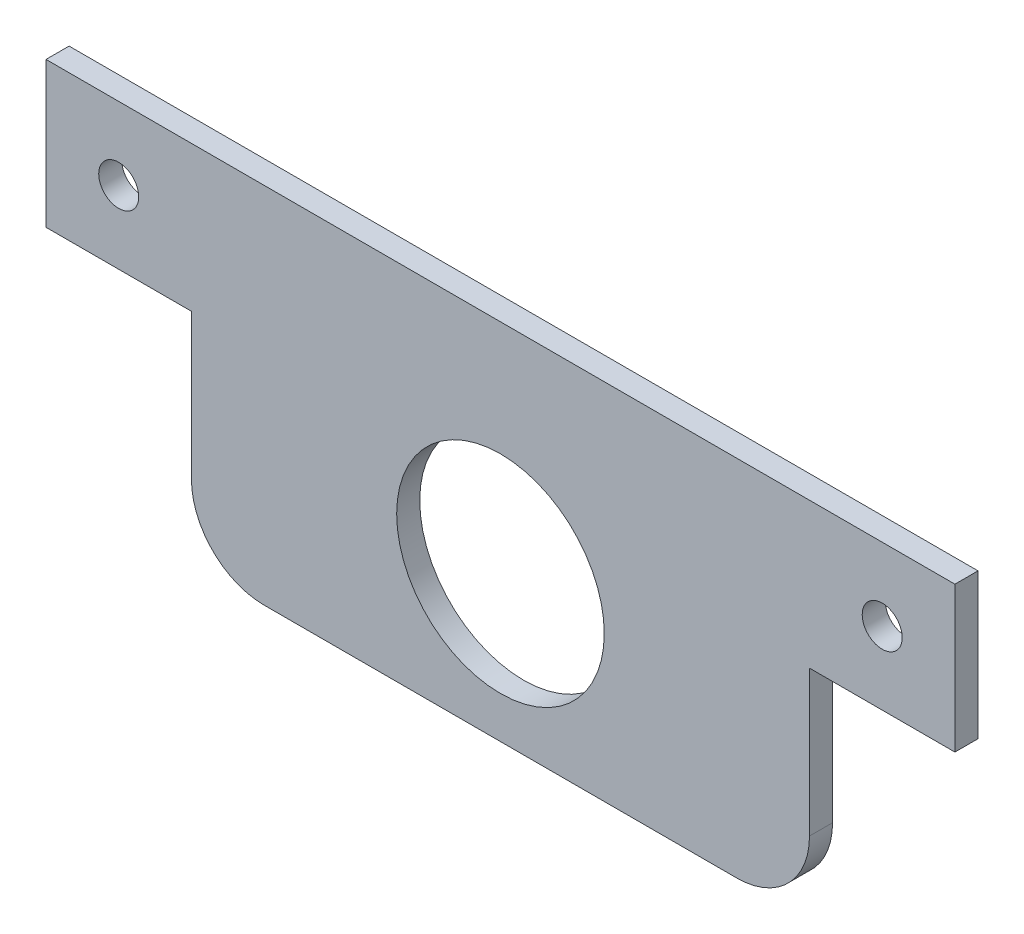
from build123d import *

# Parameters (mm, degrees)
SKETCH1_W           = 125
SKETCH1_H           = 50
BOSS_EXTRUDE1_DEPTH = 3.175
SKETCH2_R           = 14.275
CUT_EXTRUDE1_DEPTH  = 4.175
SKETCH6_R           = 2.75
SKETCH6_W           = 20
SKETCH6_H           = 30
CUT_EXTRUDE6_DEPTH  = 4.175
FILLET1_R           = 10


with BuildPart() as part:
    # Sketch1 → Boss-Extrude1 (new body)
    with BuildSketch(Plane.XY):
        with Locations((62.5, 25)):
            Rectangle(SKETCH1_W, SKETCH1_H)
    extrude(amount=BOSS_EXTRUDE1_DEPTH)

    # Sketch2 → Cut-Extrude1 (cut, through all)
    with BuildSketch(Plane.XY.offset(3.175)):
        with Locations((62.5, 20)):
            Circle(SKETCH2_R)
    extrude(amount=-CUT_EXTRUDE1_DEPTH, mode=Mode.SUBTRACT)

    # Sketch6 → Cut-Extrude6 (cut, through all)
    with BuildSketch(Plane(origin=(0, 0, 0), x_dir=(-1, 0, 0), z_dir=(0, 0, -1))):
        with Locations((-115, 40)):
            Circle(SKETCH6_R)
        with Locations((-10, 40)):
            Circle(SKETCH6_R)
        with Locations((-115, 15)):
            Rectangle(SKETCH6_W, SKETCH6_H)
        with Locations((-10, 15)):
            Rectangle(SKETCH6_W, SKETCH6_H)
    extrude(amount=-CUT_EXTRUDE6_DEPTH, mode=Mode.SUBTRACT)

    # Fillet1
    fillet1_edges = [part.edges().sort_by_distance(p)[0] for p in [
        (105, 0, 1.5875),
        (20, 0, 1.5875),
    ]]
    fillet(fillet1_edges, radius=FILLET1_R)


solid = part.part
